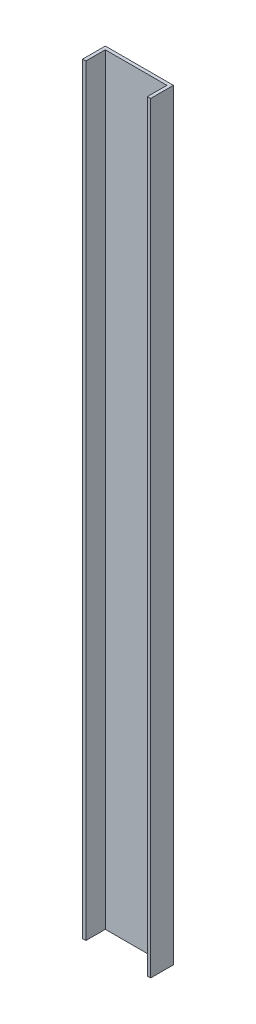
from build123d import *

# Parameters (mm, degrees)
BOSS_EXTRUDE1_DEPTH = 2350


with BuildPart() as part:
    # Sketch1 → Boss-Extrude1 (new body)
    with BuildSketch(Plane(origin=(0, 2350, 0), x_dir=(1, 0, 0), z_dir=(0, 1, 0))):
        Polygon((-10, 70), (-10, 0), (0, 0), (0, 60), (190, 60), (190, 0), (200, 0), (200, 70), align=None)
    extrude(amount=-BOSS_EXTRUDE1_DEPTH)


solid = part.part
